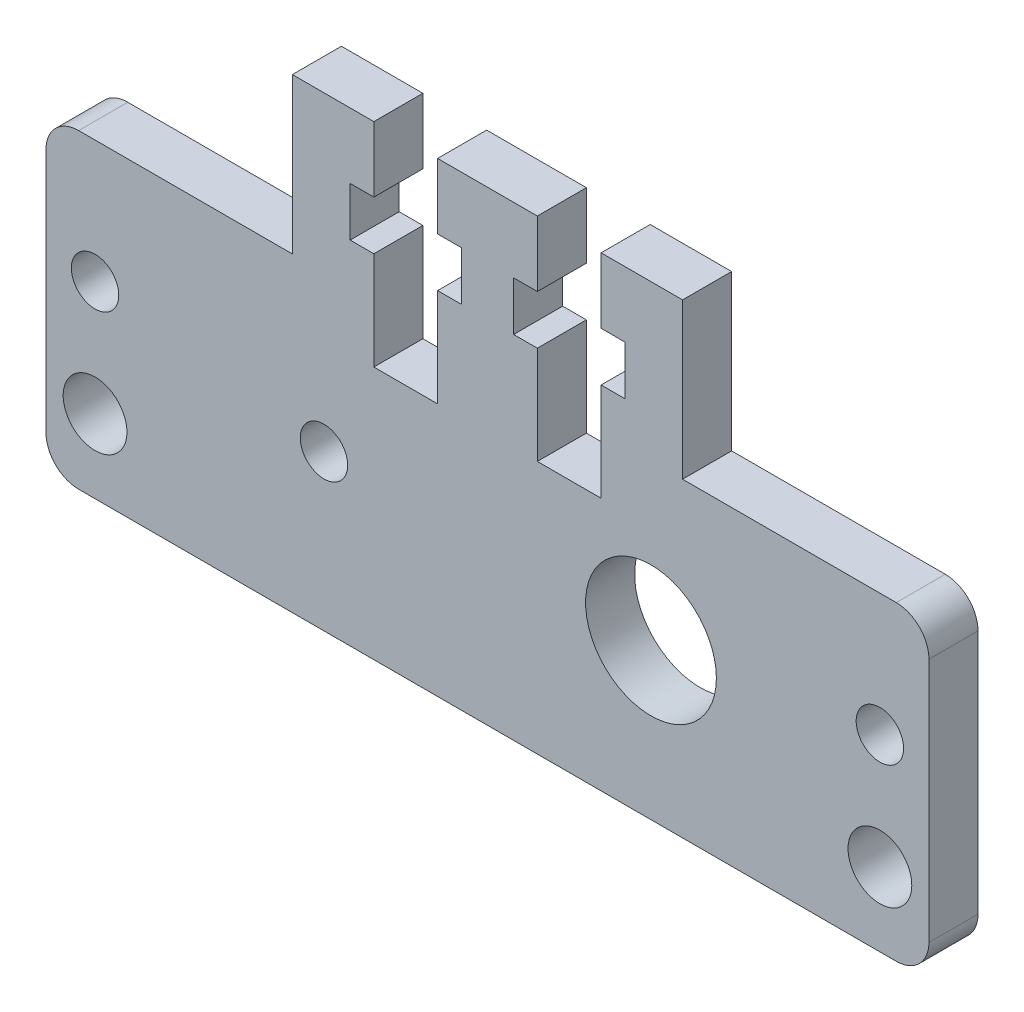
from build123d import *

# Parameters (mm, degrees)
SKETCH1_R           = 1.95
SKETCH1_R_2         = 4
SKETCH1_R_3         = 1.45
BOSS_EXTRUDE1_DEPTH = 3


with BuildPart() as part:
    # Sketch1 → Boss-Extrude1 (new body)
    with BuildSketch(Plane.XY.offset(-5.551615438)):
        with BuildLine():
            Line((-25.464626351, 10.13731735), (-12.396849296, 10.13731735))
            Line((-12.396849296, 10.13731735), (-12.396849296, 19.63731735))
            Line((-12.396849296, 19.63731735), (-7.414626351, 19.63731735))
            Line((-7.414626351, 19.63731735), (-7.414626351, 15.63731735))
            Line((-7.414626351, 15.63731735), (-8.864626351, 15.63731735))
            Line((-8.864626351, 15.63731735), (-8.864626351, 12.63731735))
            Line((-8.864626351, 12.63731735), (-7.414626351, 12.63731735))
            Line((-7.414626351, 12.63731735), (-7.414626351, 6.63731735))
            Line((-7.414626351, 6.63731735), (-3.514626351, 6.63731735))
            Line((-3.514626351, 6.63731735), (-3.514626351, 12.63731735))
            Line((-3.514626351, 12.63731735), (-2.064626351, 12.63731735))
            Line((-2.064626351, 12.63731735), (-2.064626351, 15.63731735))
            Line((-2.064626351, 15.63731735), (-3.514626351, 15.63731735))
            Line((-3.514626351, 15.63731735), (-3.514626351, 19.63731735))
            Line((-3.514626351, 19.63731735), (2.585373649, 19.63731735))
            Line((2.585373649, 19.63731735), (2.585373649, 15.63731735))
            Line((2.585373649, 15.63731735), (1.135373649, 15.63731735))
            Line((1.135373649, 15.63731735), (1.135373649, 12.63731735))
            Line((1.135373649, 12.63731735), (2.585373649, 12.63731735))
            Line((2.585373649, 12.63731735), (2.585373649, 6.63731735))
            Line((2.585373649, 6.63731735), (6.485373649, 6.63731735))
            Line((6.485373649, 6.63731735), (6.485373649, 12.63731735))
            Line((6.485373649, 12.63731735), (7.935373649, 12.63731735))
            Line((7.935373649, 12.63731735), (7.935373649, 15.63731735))
            Line((7.935373649, 15.63731735), (6.485373649, 15.63731735))
            Line((6.485373649, 15.63731735), (6.485373649, 19.63731735))
            Line((6.485373649, 19.63731735), (11.467596593, 19.63731735))
            Line((11.467596593, 19.63731735), (11.467596593, 10.13731735))
            Line((11.467596593, 10.13731735), (24.535373649, 10.13731735))
            ThreePointArc((24.535373649, 10.13731735), (25.949587211, 9.551530913), (26.535373649, 8.13731735))
            Line((26.535373649, 8.13731735), (26.535373649, -6.86268265))
            ThreePointArc((26.535373649, -6.86268265), (25.949587211, -8.276896212), (24.535373649, -8.86268265))
            Line((24.535373649, -8.86268265), (-10, -8.86268265))
            Line((-10, -8.86268265), (-25.464626351, -8.86268265))
            ThreePointArc((-25.464626351, -8.86268265), (-26.878839913, -8.276896212), (-27.464626351, -6.86268265))
            Line((-27.464626351, -6.86268265), (-27.464626351, 8.13731735))
            ThreePointArc((-27.464626351, 8.13731735), (-26.878839913, 9.551530913), (-25.464626351, 10.13731735))
        make_face()
        with Locations((-24.464626351, -4.36268265)):
            Circle(SKETCH1_R, mode=Mode.SUBTRACT)
        with Locations((23.535373649, -4.36268265)):
            Circle(SKETCH1_R, mode=Mode.SUBTRACT)
        with Locations((9.535373649, 0.63731735)):
            Circle(SKETCH1_R_2, mode=Mode.SUBTRACT)
        with Locations((-10.464626351, 0.63731735)):
            Circle(SKETCH1_R_3, mode=Mode.SUBTRACT)
        with Locations((-24.464626351, 2.63731735)):
            Circle(SKETCH1_R_3, mode=Mode.SUBTRACT)
        with Locations((23.535373649, 2.63731735)):
            Circle(SKETCH1_R_3, mode=Mode.SUBTRACT)
    extrude(amount=BOSS_EXTRUDE1_DEPTH)


solid = part.part
